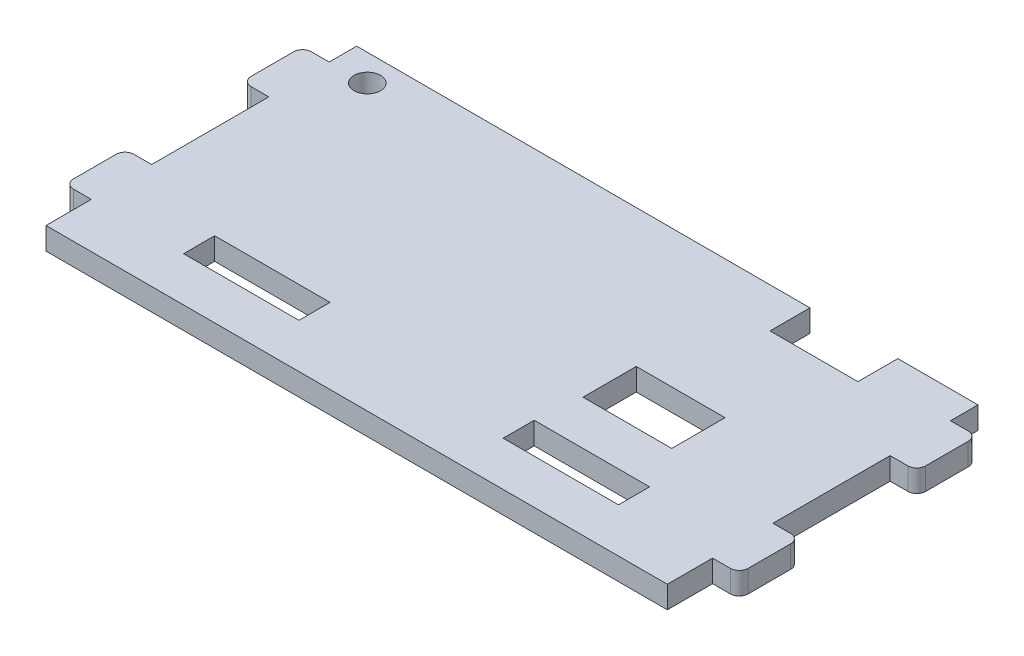
from build123d import *

# Parameters (mm, degrees)
SKETCH_1_W          = 76
SKETCH_1_H          = 35
EXTRUDE_1_DEPTH     = 2.5
SKETCH_2_W          = 13
SKETCH_2_H          = 3.5
CUT_EXTRUDE_1_DEPTH = 3.5
SKETCH_3_W          = 3
SKETCH_3_H          = 5.1
SKETCH_3_H_2        = 3.1
SKETCH_3_H_3        = 13.2
CUT_EXTRUDE_2_DEPTH = 3.5
FILLET_1_R          = 1
SKETCH_4_R          = 1.5
SKETCH_4_W          = 9.9
SKETCH_4_H          = 4.5
CUT_EXTRUDE_3_DEPTH = 3.5
SKETCH_5_W          = 10
SKETCH_5_H          = 6
CUT_EXTRUDE_4_DEPTH = 3.5


with BuildPart() as part:
    # 草图1 → 凸台-拉伸1 (new body)
    with BuildSketch(Plane(origin=(0, 0, 0), x_dir=(1, 0, 0), z_dir=(0, 1, 0))):
        Rectangle(SKETCH_1_W, SKETCH_1_H)
    extrude(amount=EXTRUDE_1_DEPTH)

    # 草图2 → 切除-拉伸1 (cut, through all)
    with BuildSketch(Plane(origin=(0, 2.5, 0), x_dir=(1, 0, 0), z_dir=(0, 1, 0))):
        with Locations((-18, -10.75)):
            Rectangle(SKETCH_2_W, SKETCH_2_H)
        with Locations((18, -10.75)):
            Rectangle(SKETCH_2_W, SKETCH_2_H)
    extrude(amount=-CUT_EXTRUDE_1_DEPTH, mode=Mode.SUBTRACT)

    # 草图3 → 切除-拉伸2 (cut, through all)
    with BuildSketch(Plane(origin=(0, 2.5, 0), x_dir=(1, 0, 0), z_dir=(0, 1, 0))):
        with Locations((-36.5, -14.95)):
            Rectangle(SKETCH_3_W, SKETCH_3_H)
        with Locations((-36.5, 15.95)):
            Rectangle(SKETCH_3_W, SKETCH_3_H_2)
        with Locations((-36.5, 1)):
            Rectangle(SKETCH_3_W, SKETCH_3_H_3)
        with Locations((36.5, -14.95)):
            Rectangle(SKETCH_3_W, SKETCH_3_H)
        with Locations((36.5, 1)):
            Rectangle(SKETCH_3_W, SKETCH_3_H_3)
        with Locations((36.5, 15.95)):
            Rectangle(SKETCH_3_W, SKETCH_3_H_2)
    extrude(amount=-CUT_EXTRUDE_2_DEPTH, mode=Mode.SUBTRACT)

    # 圆角1
    fillet_1_edges = [part.edges().sort_by_distance(p)[0] for p in [
        (38, 1.25, -7.6),
        (38, 1.25, 5.6),
        (38, 1.25, -14.4),
        (-38, 1.25, 12.4),
        (-38, 1.25, -14.4),
        (-38, 1.25, 5.6),
        (-38, 1.25, -7.6),
        (38, 1.25, 12.4),
    ]]
    fillet(fillet_1_edges, radius=FILLET_1_R)

    # 草图4 → 切除-拉伸3 (cut, through all)
    with BuildSketch(Plane(origin=(0, 2.5, 0), x_dir=(1, 0, 0), z_dir=(0, 1, 0))):
        with Locations((-30.8, 14.5)):
            Circle(SKETCH_4_R)
        with Locations((21.018135054, 15.25)):
            Rectangle(SKETCH_4_W, SKETCH_4_H)
    extrude(amount=-CUT_EXTRUDE_3_DEPTH, mode=Mode.SUBTRACT)

    # 草图5 → 切除-拉伸4 (cut, through all)
    with BuildSketch(Plane(origin=(0, 2.5, 0), x_dir=(1, 0, 0), z_dir=(0, 1, 0))):
        with Locations((17, -1)):
            Rectangle(SKETCH_5_W, SKETCH_5_H)
    extrude(amount=-CUT_EXTRUDE_4_DEPTH, mode=Mode.SUBTRACT)


solid = part.part
